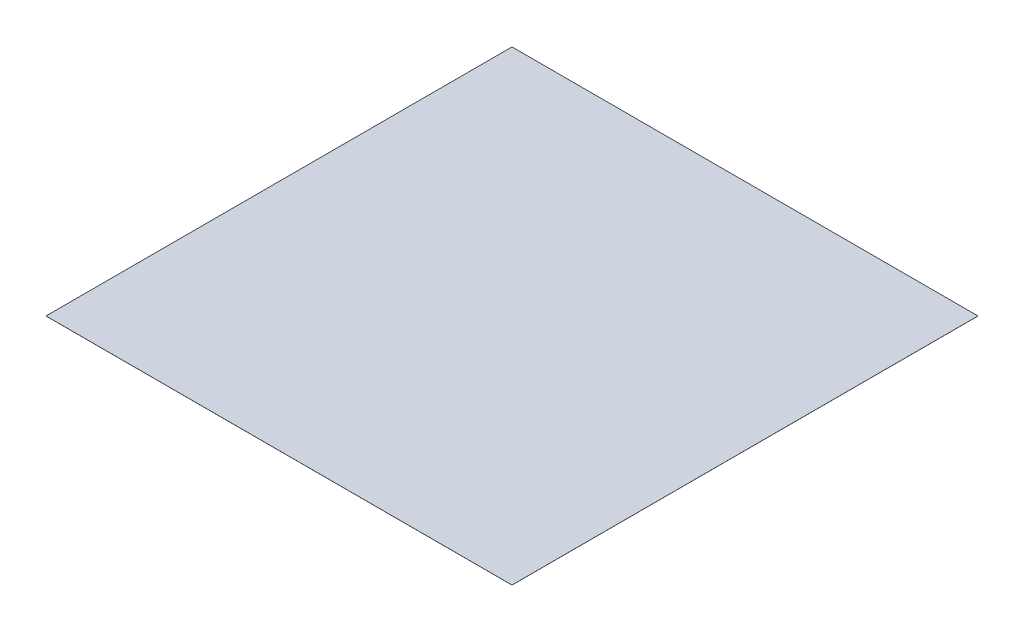
from build123d import *

# Parameters (mm, degrees)
SKETCH1_W           = 2032
SKETCH1_H           = 2032
BOSS_EXTRUDE1_DEPTH = 0.254


with BuildPart() as part:
    # Sketch1 → Boss-Extrude1 (new body)
    with BuildSketch(Plane(origin=(0, 0, 0), x_dir=(1, 0, 0), z_dir=(0, 1, 0))):
        Rectangle(SKETCH1_W, SKETCH1_H)
    extrude(amount=BOSS_EXTRUDE1_DEPTH)


solid = part.part
